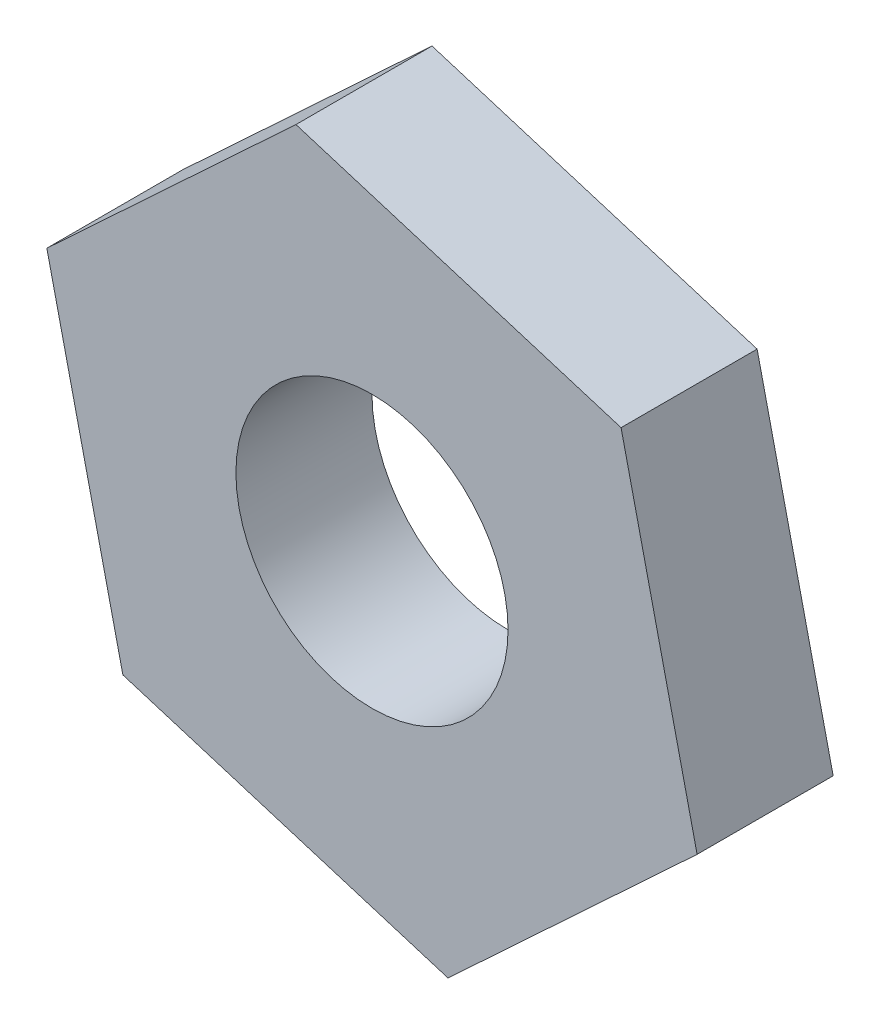
from build123d import *

# Parameters (mm, degrees)
EXTRUDE_1_DEPTH     = 4
SKETCH_2_R          = 4
CUT_EXTRUDE_1_DEPTH = 5


with BuildPart() as part:
    # 草图1 → 凸台-拉伸1 (new body)
    with BuildSketch(Plane.XY):
        Polygon((-9.558782069, 2.93763261), (-7.323455502, -6.809331797), (2.235326568, -9.746964406), (9.558782069, -2.93763261), (7.323455502, 6.809331797), (-2.235326568, 9.746964406), align=None)
    extrude(amount=EXTRUDE_1_DEPTH)

    # 草图2 → 切除-拉伸1 (cut, through all)
    with BuildSketch(Plane.XY.offset(4)):
        Circle(SKETCH_2_R)
    extrude(amount=-CUT_EXTRUDE_1_DEPTH, mode=Mode.SUBTRACT)


solid = part.part
